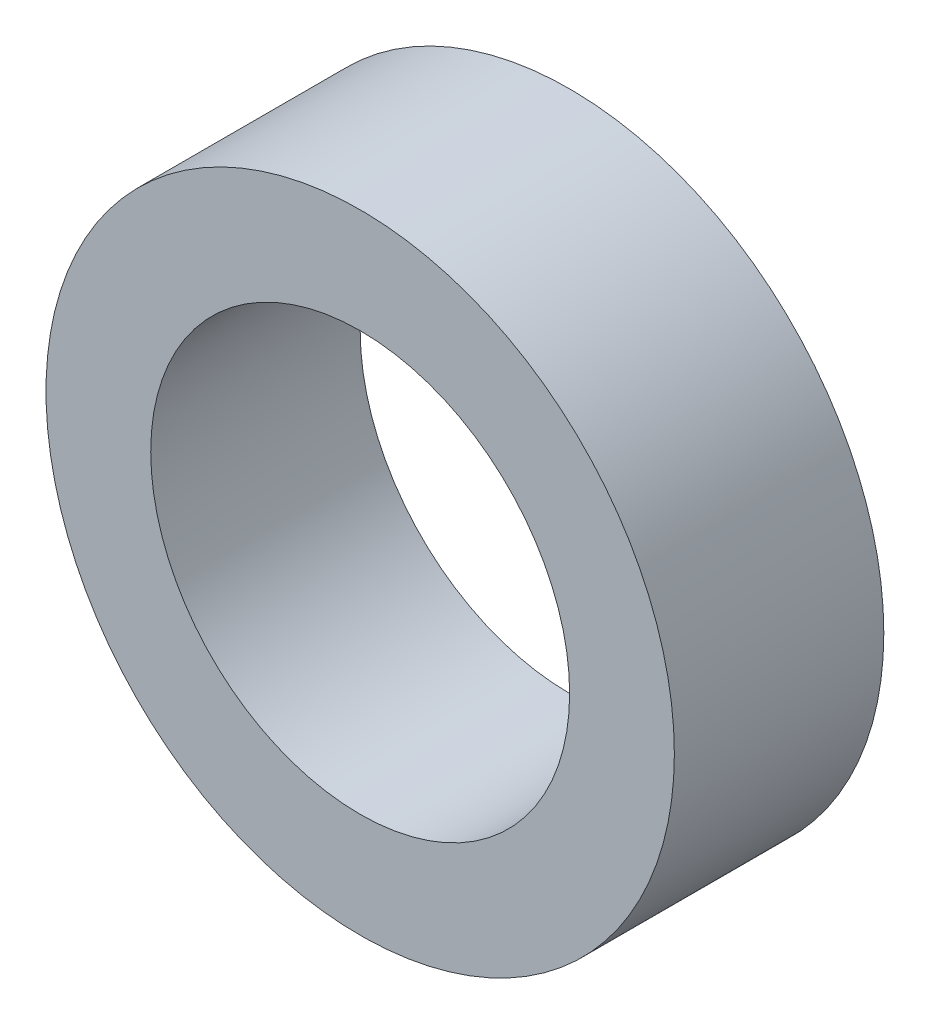
from build123d import *

# Parameters (mm, degrees)
SKETCH1_R           = 6
SKETCH1_R_2         = 4
BOSS_EXTRUDE1_DEPTH = 4


with BuildPart() as part:
    # Sketch1 → Boss-Extrude1 (new body)
    with BuildSketch(Plane.XY):
        Circle(SKETCH1_R)
        Circle(SKETCH1_R_2, mode=Mode.SUBTRACT)
    extrude(amount=BOSS_EXTRUDE1_DEPTH)


solid = part.part
